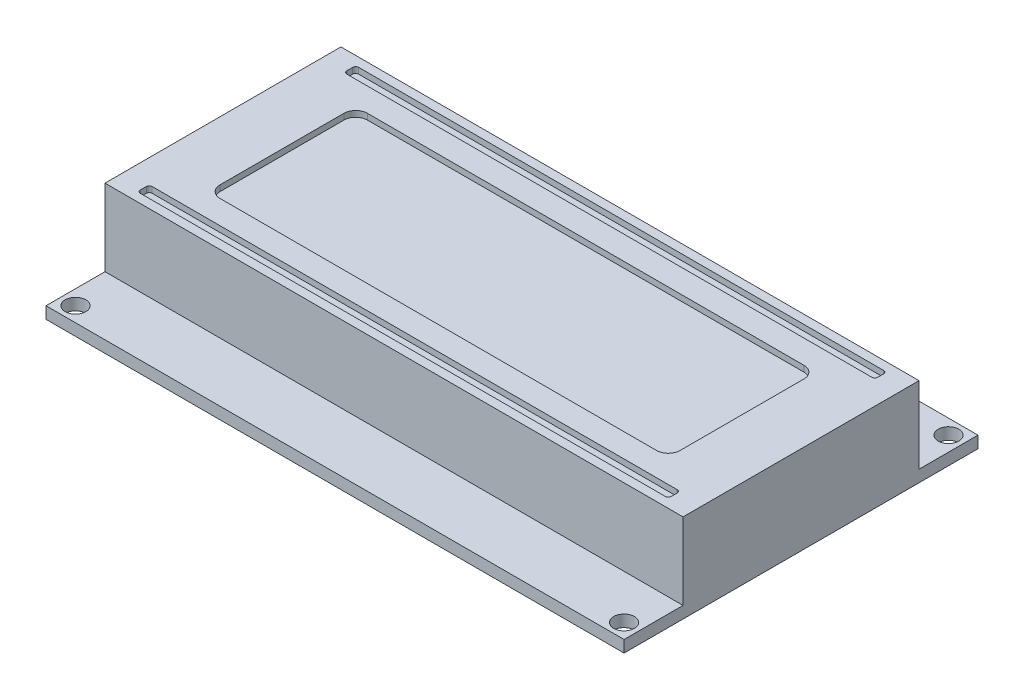
from build123d import *

# Parameters (mm, degrees)
SKETCH1_W               = 150
SKETCH1_H               = 55
SKETCH1_R               = 1.5
BOSS_EXTRUDE1_DEPTH     = 2
SKETCH2_R               = 6
BOSS_EXTRUDE2_DEPTH     = 10
SKETCH3_W               = 12
SKETCH3_H               = 12
BOSS_EXTRUDE3_DEPTH     = 25
SKETCH4_W               = 5
SKETCH4_H               = 5
SKETCH4_W_2             = 41
SKETCH4_H_2             = 3
BOSS_EXTRUDE4_DEPTH     = 5
SKETCH5_W               = 41
SKETCH5_H               = 3
SKETCH5_W_2             = 5
SKETCH5_H_2             = 5
SKETCH5_R               = 1.5
CUT_EXTRUDE1_DEPTH      = 2
SKETCH6_W               = 12
SKETCH6_H               = 12
CUT_EXTRUDE2_DEPTH      = 13
SKETCH7_W               = 12
SKETCH7_H               = 12
SKETCH7_R               = 3.5
CUT_EXTRUDE3_DEPTH      = 7
SKETCH8_R               = 1.25
CUT_EXTRUDE4_DEPTH      = 5
BOSS_EXTRUDE5_DEPTH     = 3
SKETCH10_W              = 25
SKETCH10_H              = 1.5
CUT_EXTRUDE5_DEPTH      = 18
SKETCH11_W              = 98
SKETCH11_H              = 60
SKETCH11_R              = 1.75
BOSS_EXTRUDE6_DEPTH     = 2
SKETCH12_W              = 98
SKETCH12_H              = 40
BOSS_EXTRUDE7_DEPTH     = 13
CUT_EXTRUDE6_DEPTH      = 1
SKETCH14_W              = 25
SKETCH14_H              = 1.5
BOSS_EXTRUDE8_DEPTH     = 29
CUT_EXTRUDE7_DEPTH      = 76
CUT_EXTRUDE7_DEPTH_BACK = 10
SKETCH16_W              = 98
SKETCH16_H              = 8
CUT_EXTRUDE8_DEPTH      = 69


with BuildPart() as part:
    # Sketch1 → Boss-Extrude1 (new body)
    with BuildSketch(Plane(origin=(0, 0, 0), x_dir=(1, 0, 0), z_dir=(0, 1, 0))):
        with Locations((75, 27.5)):
            Rectangle(SKETCH1_W, SKETCH1_H)
        with Locations((3, 52)):
            Circle(SKETCH1_R, mode=Mode.SUBTRACT)
        with Locations((147, 52)):
            Circle(SKETCH1_R, mode=Mode.SUBTRACT)
        with Locations((147, 3)):
            Circle(SKETCH1_R, mode=Mode.SUBTRACT)
        with Locations((3, 3)):
            Circle(SKETCH1_R, mode=Mode.SUBTRACT)
    extrude(amount=BOSS_EXTRUDE1_DEPTH)

    # Sketch2 → Boss-Extrude2 (add)
    with BuildSketch(Plane(origin=(0, 2, 0), x_dir=(1, 0, 0), z_dir=(0, 1, 0))):
        with Locations((13, 10)):
            Circle(SKETCH2_R)
    extrude(amount=BOSS_EXTRUDE2_DEPTH)

    # Sketch3 → Boss-Extrude3 (add)
    with BuildSketch(Plane(origin=(0, 2, 0), x_dir=(1, 0, 0), z_dir=(0, 1, 0))):
        with Locations((13, 27.5)):
            Rectangle(SKETCH3_W, SKETCH3_H)
    extrude(amount=BOSS_EXTRUDE3_DEPTH)

    # Sketch4 → Boss-Extrude4 (add)
    with BuildSketch(Plane(origin=(0, 2, 0), x_dir=(1, 0, 0), z_dir=(0, 1, 0))):
        with Locations((13, 43)):
            Rectangle(SKETCH4_W, SKETCH4_H)
        with Locations((106.5, 6.5)):
            Rectangle(SKETCH4_W_2, SKETCH4_H_2)
    extrude(amount=BOSS_EXTRUDE4_DEPTH)

    # Sketch5 → Cut-Extrude1 (cut)
    with BuildSketch(Plane(origin=(0, 7, 0), x_dir=(1, 0, 0), z_dir=(0, 1, 0))):
        with Locations((106.5, 6.5)):
            Rectangle(SKETCH5_W, SKETCH5_H)
        with Locations((13, 43)):
            Rectangle(SKETCH5_W_2, SKETCH5_H_2)
        with Locations((13, 43)):
            Circle(SKETCH5_R, mode=Mode.SUBTRACT)
    extrude(amount=-CUT_EXTRUDE1_DEPTH, mode=Mode.SUBTRACT)

    # Sketch6 → Cut-Extrude2 (cut)
    with BuildSketch(Plane(origin=(0, 27, 0), x_dir=(1, 0, 0), z_dir=(0, 1, 0))):
        with Locations((13, 27.5)):
            Rectangle(SKETCH6_W, SKETCH6_H)
        with BuildLine():
            Line((10.370614338, 26.055586264), (15.629385662, 26.055586264))
            ThreePointArc((15.629385662, 26.055586264), (13, 30.5), (10.370614338, 26.055586264))
        make_face(mode=Mode.SUBTRACT)
    extrude(amount=-CUT_EXTRUDE2_DEPTH, mode=Mode.SUBTRACT)

    # Sketch7 → Cut-Extrude3 (cut)
    with BuildSketch(Plane(origin=(0, 14, 0), x_dir=(1, 0, 0), z_dir=(0, 1, 0))):
        with Locations((13, 27.5)):
            Rectangle(SKETCH7_W, SKETCH7_H)
        with Locations((13, 27.5)):
            Circle(SKETCH7_R, mode=Mode.SUBTRACT)
    extrude(amount=-CUT_EXTRUDE3_DEPTH, mode=Mode.SUBTRACT)

    # Sketch8 → Cut-Extrude4 (cut)
    with BuildSketch(Plane(origin=(0, 12, 0), x_dir=(1, 0, 0), z_dir=(0, 1, 0))):
        with Locations((13, 10)):
            Circle(SKETCH8_R)
    extrude(amount=-CUT_EXTRUDE4_DEPTH, mode=Mode.SUBTRACT)

    # Sketch9 → Boss-Extrude5 (add)
    with BuildSketch(Plane.XZ):
        Polygon((149, -20), (131, -20), (129, -22), (124, -22), (124, -47), (149, -47), align=None)
    extrude(amount=BOSS_EXTRUDE5_DEPTH)

    # Sketch10 → Cut-Extrude5 (cut)
    with BuildSketch(Plane(origin=(149, 0, 0), x_dir=(0, 0, -1), z_dir=(1, 0, 0))):
        with Locations((33.5, -1.5)):
            Rectangle(SKETCH10_W, SKETCH10_H)
    extrude(amount=-CUT_EXTRUDE5_DEPTH, mode=Mode.SUBTRACT)

    # Sketch11 → Boss-Extrude6 (add)
    with BuildSketch(Plane(origin=(0, 5, 0), x_dir=(1, 0, 0), z_dir=(0, 1, 0))):
        with Locations((87, 34)):
            Rectangle(SKETCH11_W, SKETCH11_H)
        with Locations((40.5, 61.5)):
            Circle(SKETCH11_R, mode=Mode.SUBTRACT)
        with Locations((133.5, 61.5)):
            Circle(SKETCH11_R, mode=Mode.SUBTRACT)
        with Locations((133.5, 6.5)):
            Circle(SKETCH11_R, mode=Mode.SUBTRACT)
        with Locations((40.5, 6.5)):
            Circle(SKETCH11_R, mode=Mode.SUBTRACT)
    extrude(amount=BOSS_EXTRUDE6_DEPTH)

    # Sketch12 → Boss-Extrude7 (add)
    with BuildSketch(Plane(origin=(0, 7, 0), x_dir=(1, 0, 0), z_dir=(0, 1, 0))):
        with Locations((87, 34)):
            Rectangle(SKETCH12_W, SKETCH12_H)
    extrude(amount=BOSS_EXTRUDE7_DEPTH)

    # Sketch13 → Cut-Extrude6 (cut)
    with BuildSketch(Plane(origin=(0, 20, 0), x_dir=(1, 0, 0), z_dir=(0, 1, 0))):
        with BuildLine():
            Line((50, 46.5), (124, 46.5))
            ThreePointArc((124, 46.5), (125.414213562, 45.914213562), (126, 44.5))
            Line((126, 44.5), (126, 23.5))
            ThreePointArc((126, 23.5), (125.414213562, 22.085786438), (124, 21.5))
            Line((124, 21.5), (50, 21.5))
            ThreePointArc((50, 21.5), (48.585786438, 22.085786438), (48, 23.5))
            Line((48, 23.5), (48, 44.5))
            ThreePointArc((48, 44.5), (48.585786438, 45.914213562), (50, 46.5))
        make_face()
        with BuildLine():
            Line((42.5, 52.5), (131.5, 52.5))
            ThreePointArc((131.5, 52.5), (131.853553391, 52.353553391), (132, 52))
            Line((132, 52), (132, 51))
            ThreePointArc((132, 51), (131.853553391, 50.646446609), (131.5, 50.5))
            Line((131.5, 50.5), (42.5, 50.5))
            ThreePointArc((42.5, 50.5), (42.146446609, 50.646446609), (42, 51))
            Line((42, 51), (42, 52))
            ThreePointArc((42, 52), (42.146446609, 52.353553391), (42.5, 52.5))
        make_face()
        with BuildLine():
            Line((132, 16), (132, 17))
            ThreePointArc((132, 17), (131.853553391, 17.353553391), (131.5, 17.5))
            Line((131.5, 17.5), (42.5, 17.5))
            ThreePointArc((42.5, 17.5), (42.146446609, 17.353553391), (42, 17))
            Line((42, 17), (42, 16))
            ThreePointArc((42, 16), (42.146446609, 15.646446609), (42.5, 15.5))
            Line((42.5, 15.5), (131.5, 15.5))
            ThreePointArc((131.5, 15.5), (131.853553391, 15.646446609), (132, 16))
        make_face()
    extrude(amount=-CUT_EXTRUDE6_DEPTH, mode=Mode.SUBTRACT)

    # Sketch14 → Boss-Extrude8 (add)
    with BuildSketch(Plane(origin=(131, 0, 0), x_dir=(0, 0, -1), z_dir=(1, 0, 0))):
        with Locations((33.5, -1.5)):
            Rectangle(SKETCH14_W, SKETCH14_H)
    extrude(amount=BOSS_EXTRUDE8_DEPTH)

    # Sketch15 → Cut-Extrude7 (cut, two sides)
    with BuildSketch(Plane(origin=(0, 2, 0), x_dir=(1, 0, 0), z_dir=(0, 1, 0))) as cut_extrude7_sk:
        Polygon((38, 64), (-8.690723281, 64), (-8.690723281, -2.980686498), (38, -2.980686498), (158.556379493, -2.980686498), (158.556379493, 4), (165.16100148, 4), (165.16100148, 64), (136, 64), (136, 4), (38, 4), align=None)
    extrude(amount=CUT_EXTRUDE7_DEPTH, mode=Mode.SUBTRACT)
    extrude(cut_extrude7_sk.sketch, amount=-CUT_EXTRUDE7_DEPTH_BACK, mode=Mode.SUBTRACT)

    # Sketch16 → Cut-Extrude8 (cut)
    with BuildSketch(Plane.XY.offset(-4)):
        with Locations((87, 1)):
            Rectangle(SKETCH16_W, SKETCH16_H)
    extrude(amount=-CUT_EXTRUDE8_DEPTH, mode=Mode.SUBTRACT)


solid = part.part
